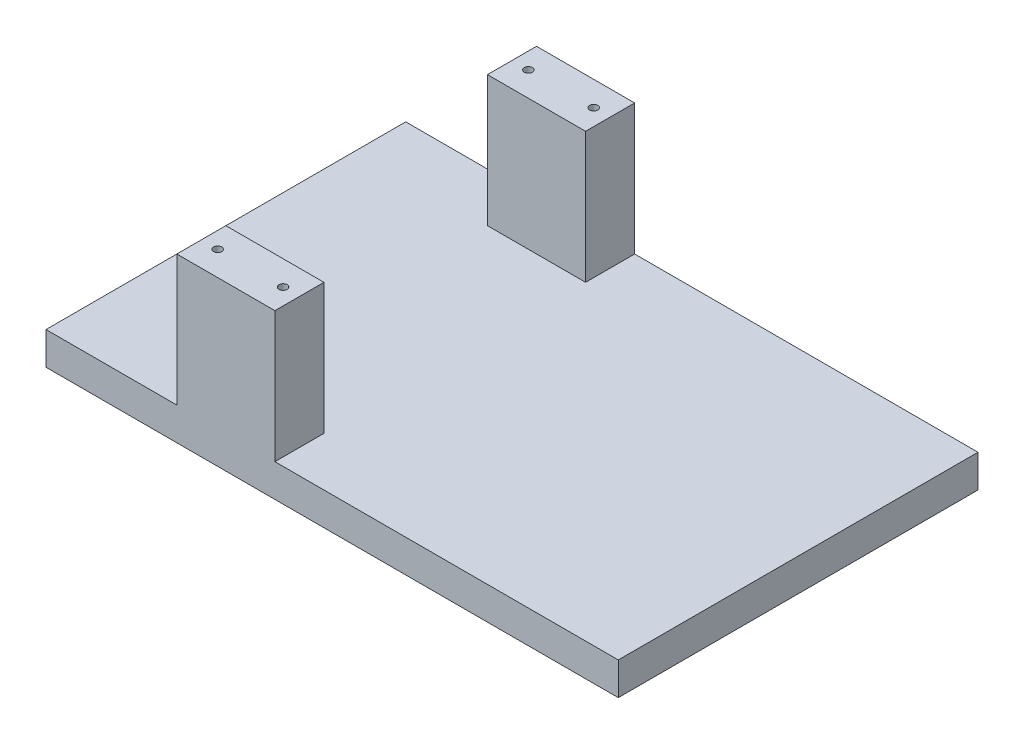
from build123d import *

# Parameters (mm, degrees)
SKETCH1_W                 = 175
SKETCH1_H                 = 110
BOSS_EXTRUDE1_DEPTH       = 10
SKETCH3_W                 = 30
SKETCH3_H                 = 15
BOSS_EXTRUDE2_DEPTH       = 40
M3X0_5_TAPPED_HOLE1_D     = 2.5
M3X0_5_TAPPED_HOLE1_DEPTH = 7.5
M3X0_5_TAPPED_HOLE1_TIP   = 0.751075774


with BuildPart() as part:
    # Sketch1 → Boss-Extrude1 (new body)
    with BuildSketch(Plane(origin=(0, 0, 0), x_dir=(1, 0, 0), z_dir=(0, 1, 0))):
        with Locations((87.5, 55)):
            Rectangle(SKETCH1_W, SKETCH1_H)
    extrude(amount=BOSS_EXTRUDE1_DEPTH)

    # Sketch3 → Boss-Extrude2 (add)
    with BuildSketch(Plane(origin=(0, 10, 0), x_dir=(1, 0, 0), z_dir=(0, 1, 0))):
        with Locations((55, 7.5)):
            Rectangle(SKETCH3_W, SKETCH3_H)
        with Locations((55, 102.5)):
            Rectangle(SKETCH3_W, SKETCH3_H)
    extrude(amount=BOSS_EXTRUDE2_DEPTH)

    # M3x0.5 Tapped Hole1
    with Locations(Plane(origin=(0, 50, 0), x_dir=(-1, 0, 0), z_dir=(0, 1, 0))):
        with Locations((-45, -7.5), (-65, -7.5), (-45, -102.5), (-65, -102.5)):
            Hole(M3X0_5_TAPPED_HOLE1_D / 2, depth=M3X0_5_TAPPED_HOLE1_DEPTH)
            with Locations((0, 0, -(M3X0_5_TAPPED_HOLE1_DEPTH + M3X0_5_TAPPED_HOLE1_TIP / 2))):  # 118° drill point
                Cone(0, M3X0_5_TAPPED_HOLE1_D / 2, M3X0_5_TAPPED_HOLE1_TIP, mode=Mode.SUBTRACT)


solid = part.part
